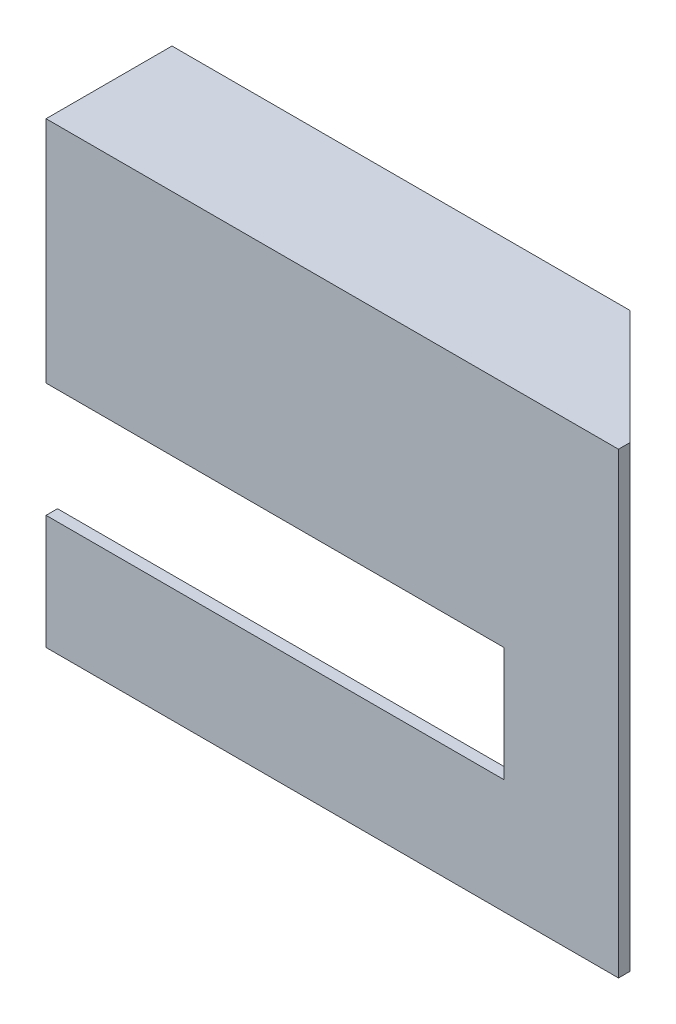
from build123d import *

# Parameters (mm, degrees)
EXTRUDE_2_DEPTH = 1
SKETCH_3_W      = 50
SKETCH_3_H      = 1
EXTRUDE_4_DEPTH = 10
CHAMFER_1_SIZE  = 10


with BuildPart() as part:
    # 草图1 → 凸台-拉伸2 (new body)
    with BuildSketch(Plane.XY):
        Polygon((19.887012794, -8.045194882), (19.887012794, -18.045194882), (-20.112987206, -18.045194882), (-20.112987206, -28.045194882), (29.887012794, -28.045194882), (29.887012794, -17.764313667), (29.887012794, 11.954805118), (-20.112987206, 11.954805118), (-20.112987206, -8.045194882), align=None)
    extrude(amount=EXTRUDE_2_DEPTH)

    # 草图3 → 凸台-拉伸4 (add)
    with BuildSketch(Plane(origin=(0, 0, 0), x_dir=(-1, 0, 0), z_dir=(0, 0, -1))):
        with Locations((-4.887012794, 11.454805118)):
            Rectangle(SKETCH_3_W, SKETCH_3_H)
    extrude(amount=EXTRUDE_4_DEPTH)

    # 倒角1
    chamfer_1_edges = [part.edges().sort_by_distance(p)[0] for p in [
        (29.887012794, 11.454805118, -10),
    ]]
    chamfer(chamfer_1_edges, length=CHAMFER_1_SIZE)


solid = part.part
